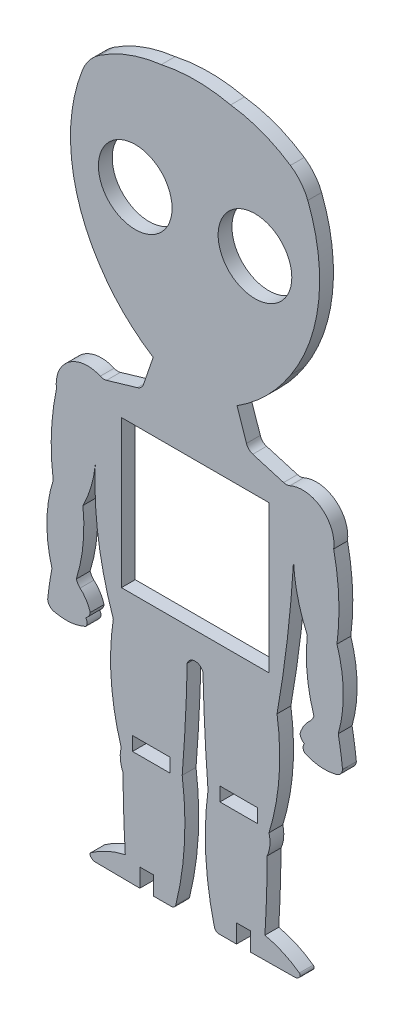
from build123d import *

# Parameters (mm, degrees)
MODEL_R                 = 8
MODEL_W                 = 8.2
MODEL_H                 = 3
SALIENTE_EXTRUIR1_DEPTH = 3


with BuildPart() as part:
    # Model → Saliente-Extruir1 (new body)
    with BuildSketch(Plane.XY):
        with BuildLine():
            Line((53.481445034, 31.38247243), (46.779993349, 33.353487631))
            ThreePointArc((46.779993349, 33.353487631), (45.927013388, 33.861110925), (45.423137443, 34.716309882))
            Line((45.423137443, 34.716309882), (43.357228049, 40.767605918))
            ThreePointArc((43.357228049, 40.767605918), (49.8242529, 45.957956881), (55.030233707, 52.412406306))
            ThreePointArc((55.030233707, 52.412406306), (61.093598066, 69.288732485), (58.730938319, 87.064913502))
            ThreePointArc((58.730938319, 87.064913502), (57.207808393, 89.703172008), (54.961022773, 91.760424326))
            ThreePointArc((54.961022773, 91.760424326), (48.760554591, 94.970135555), (41.983416035, 96.648958014))
            ThreePointArc((41.983416035, 96.648958014), (34.455707931, 97.499868783), (26.92255254, 96.698614587))
            ThreePointArc((26.92255254, 96.698614587), (19.94147438, 95.017139449), (13.543281779, 91.757393696))
            ThreePointArc((13.543281779, 91.757393696), (11.296797252, 89.699812596), (9.774053436, 87.061331216))
            ThreePointArc((9.774053436, 87.061331216), (7.413995161, 69.284804627), (13.479829214, 52.409365969))
            ThreePointArc((13.479829214, 52.409365969), (18.686734846, 45.955698119), (25.154492019, 40.766303923))
            Line((25.154492019, 40.766303923), (23.089449249, 34.714697754))
            ThreePointArc((23.089449249, 34.714697754), (22.585696773, 33.859426062), (21.732790104, 33.351679631))
            Line((21.732790104, 33.351679631), (15.03162304, 31.379696979))
            ThreePointArc((15.03162304, 31.379696979), (14.337279285, 31.302558661), (13.658765154, 31.468938177))
            ThreePointArc((13.658765154, 31.468938177), (6.813868189, 30.682998994), (4.157550352, 24.325775512))
            ThreePointArc((4.157550352, 24.325775512), (3.052384752, 15.584544005), (3.445376772, 6.78249444))
            ThreePointArc((3.445376772, 6.78249444), (2.079974129, -1.555345588), (3.171410736, -9.933451987))
            ThreePointArc((3.171410736, -9.933451987), (2.64421566, -13.051552622), (2.238579914, -16.187783777))
            ThreePointArc((2.238579914, -16.187783777), (2.76704769, -17.326785827), (3.90620228, -17.854924712))
            ThreePointArc((3.90620228, -17.854924712), (7.260899106, -18.072090773), (10.49984033, -17.171862116))
            ThreePointArc((10.49984033, -17.171862116), (10.811965124, -16.338126213), (10.499599615, -15.504480466))
            ThreePointArc((10.499599615, -15.504480466), (11.162118239, -14.900674558), (11.484662699, -14.0643268))
            ThreePointArc((11.484662699, -14.0643268), (10.631367301, -12.166232415), (9.28624721, -10.578300657))
            ThreePointArc((9.28624721, -10.578300657), (8.805524833, -9.975430237), (8.452370377, -9.289989739))
            ThreePointArc((8.452370377, -9.289989739), (9.932418252, -2.08907189), (9.895592327, 5.262281961))
            ThreePointArc((9.895592327, 5.262281961), (11.66577443, 9.648300332), (12.584225099, 14.288036336))
            ThreePointArc((12.584225099, 14.288036336), (13.262246612, 0.566960759), (16.497509918, -12.784469858))
            ThreePointArc((16.497509918, -12.784469858), (16.042177417, -24.524016518), (18.211841217, -36.070307803))
            ThreePointArc((18.211841217, -36.070307803), (18.02570309, -38.378850147), (18.612581504, -40.61929405))
            ThreePointArc((18.612581504, -40.61929405), (18.748290938, -48.20736643), (19.104485347, -55.78828887))
            ThreePointArc((19.104485347, -55.78828887), (15.202287094, -57.1012499), (11.634214393, -59.155483354))
            ThreePointArc((11.634214393, -59.155483354), (11.43855886, -59.470730285), (11.514005122, -59.834006456))
            ThreePointArc((11.514005122, -59.834006456), (12.025516155, -60.292514594), (12.695797103, -60.442836581))
            Line((12.695797103, -60.442836581), (22.259216422, -60.533409729))
            Line((22.259216422, -60.533409729), (22.259232154, -56.531748667))
            Line((22.259232154, -56.531748667), (25.259232154, -56.531748667))
            Line((25.259232154, -56.531748667), (25.259232342, -60.533048512))
            Line((25.259232342, -60.533048512), (29.098103748, -60.532494304))
            ThreePointArc((29.098103748, -60.532494304), (29.711184017, -60.322402882), (30.066706369, -59.780545262))
            ThreePointArc((30.066706369, -59.780545262), (31.946344773, -47.306061086), (31.46168815, -34.700074258))
            ThreePointArc((31.46168815, -34.700074258), (32.162582874, -23.89009615), (32.552547443, -13.064441077))
            ThreePointArc((32.552547443, -13.064441077), (34.246727454, -11.820907742), (35.966107002, -13.029359245))
            ThreePointArc((35.966107002, -13.029359245), (36.368868995, -23.871724918), (37.060905712, -34.699476107))
            ThreePointArc((37.060905712, -34.699476107), (36.577860738, -47.305611007), (38.45911007, -59.779939467))
            ThreePointArc((38.45911007, -59.779939467), (38.814710645, -60.321745755), (39.427821238, -60.531748667))
            Line((39.427821238, -60.531748667), (43.259232154, -60.531748667))
            Line((43.259232154, -60.531748667), (43.259232154, -56.531748667))
            Line((43.259232154, -56.531748667), (46.259232154, -56.531748667))
            Line((46.259232154, -56.531748667), (46.259232154, -60.531748667))
            Line((46.259232154, -60.531748667), (55.830114769, -60.439722986))
            ThreePointArc((55.830114769, -60.439722986), (56.500374008, -60.289304234), (57.011818842, -59.830722256))
            ThreePointArc((57.011818842, -59.830722256), (57.087212657, -59.467435196), (56.891511615, -59.152216515))
            ThreePointArc((56.891511615, -59.152216515), (53.335182459, -57.072918402), (49.420928579, -55.788560868))
            ThreePointArc((49.420928579, -55.788560868), (49.776142638, -48.206407611), (49.910836364, -40.617133427))
            ThreePointArc((49.910836364, -40.617133427), (50.497421978, -38.376559304), (50.310964473, -36.06799077))
            ThreePointArc((50.310964473, -36.06799077), (52.490190754, -24.554218645), (52.051420468, -12.844246127))
            ThreePointArc((52.051420468, -12.844246127), (54.289526358, 2.333645055), (55.635574328, 17.616499945))
            ThreePointArc((55.635574328, 17.616499945), (56.545662292, 11.300275423), (58.621246197, 5.265799159))
            ThreePointArc((58.621246197, 5.265799159), (58.585481568, -2.085559931), (60.066569006, -9.286264035))
            ThreePointArc((60.066569006, -9.286264035), (59.713513509, -9.97175551), (59.232878172, -10.574695324))
            ThreePointArc((59.232878172, -10.574695324), (57.88798734, -12.162821257), (57.034965974, -14.06103881))
            ThreePointArc((57.034965974, -14.06103881), (57.357631173, -14.897339994), (58.020236959, -15.50105025))
            ThreePointArc((58.020236959, -15.50105025), (57.707991805, -16.334741084), (58.020236959, -17.168431917))
            ThreePointArc((58.020236959, -17.168431917), (61.259308114, -18.068192968), (64.613973553, -17.850542599))
            ThreePointArc((64.613973553, -17.850542599), (65.753051885, -17.322239264), (66.28135522, -16.183160932))
            ThreePointArc((66.28135522, -16.183160932), (65.875266709, -13.04698837), (65.347621487, -9.928963878))
            ThreePointArc((65.347621487, -9.928963878), (66.437848557, -1.550699998), (65.071242216, 6.786942824))
            ThreePointArc((65.071242216, 6.786942824), (65.462963502, 15.589049032), (64.356535965, 24.330120898))
            ThreePointArc((64.356535965, 24.330120898), (61.699300379, 30.686960828), (54.854290022, 31.471911822))
            ThreePointArc((54.854290022, 31.471911822), (54.175799918, 31.305434353), (53.481445034, 31.38247243))
        make_face()
        with Locations((21.259232154, 70.846618638)):
            Circle(MODEL_R, mode=Mode.SUBTRACT)
        with Locations((47.259232154, 70.846618638)):
            Circle(MODEL_R, mode=Mode.SUBTRACT)
        Polygon((34.759232154, 26.002609393), (50.259232154, 26.002609393), (50.259232154, -5.997390607), (18.259232154, -5.997390607), (18.259232154, 26.002609393), (33.759232154, 26.002609393), align=None, mode=Mode.SUBTRACT)
        with Locations((24.759438839, -34.100057584)):
            Rectangle(MODEL_W, MODEL_H, mode=Mode.SUBTRACT)
        with Locations((43.759438839, -34.100057584)):
            Rectangle(MODEL_W, MODEL_H, mode=Mode.SUBTRACT)
    extrude(amount=SALIENTE_EXTRUIR1_DEPTH)


solid = part.part
